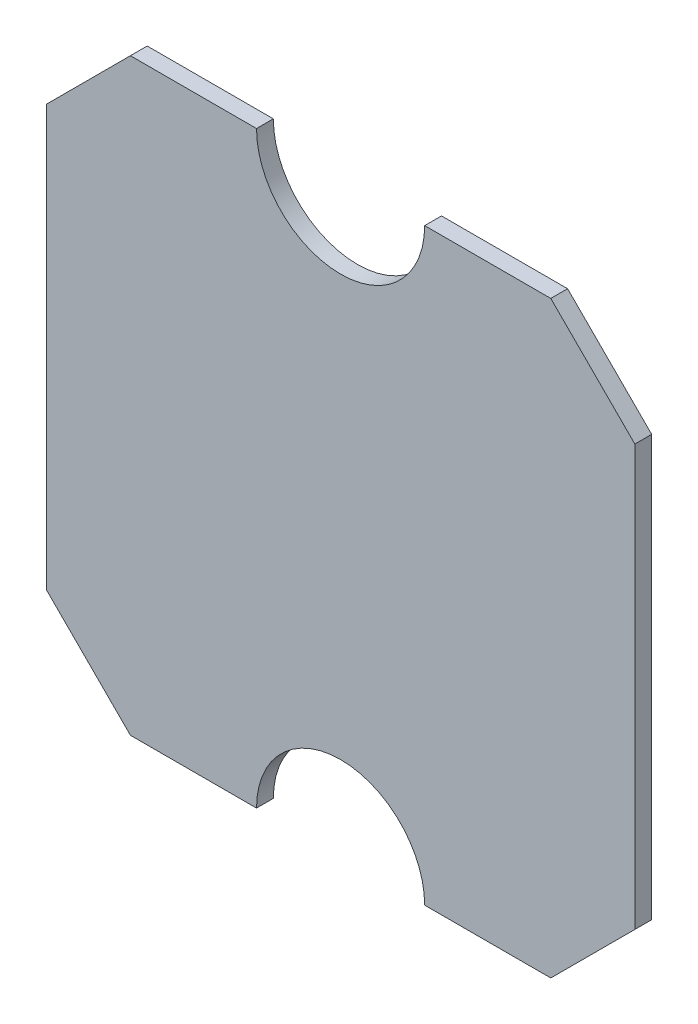
from build123d import *

# Parameters (mm, degrees)
BOSS_EXTRUDE1_DEPTH = 5


with BuildPart() as part:
    # Sketch1 → Boss-Extrude1 (new body, symmetric)
    with BuildSketch(Plane.XY):
        with BuildLine():
            Line((175, 125), (175, -125))
            Line((175, -125), (125, -175))
            Line((125, -175), (50, -175))
            ThreePointArc((50, -175), (0, -125), (-50, -175))
            Line((-50, -175), (-125, -175))
            Line((-125, -175), (-175, -125))
            Line((-175, -125), (-175, 125))
            Line((-175, 125), (-125, 175))
            Line((-125, 175), (-50, 175))
            ThreePointArc((-50, 175), (0, 125), (50, 175))
            Line((50, 175), (125, 175))
            Line((125, 175), (175, 125))
        make_face()
    extrude(amount=BOSS_EXTRUDE1_DEPTH, both=True)


solid = part.part
